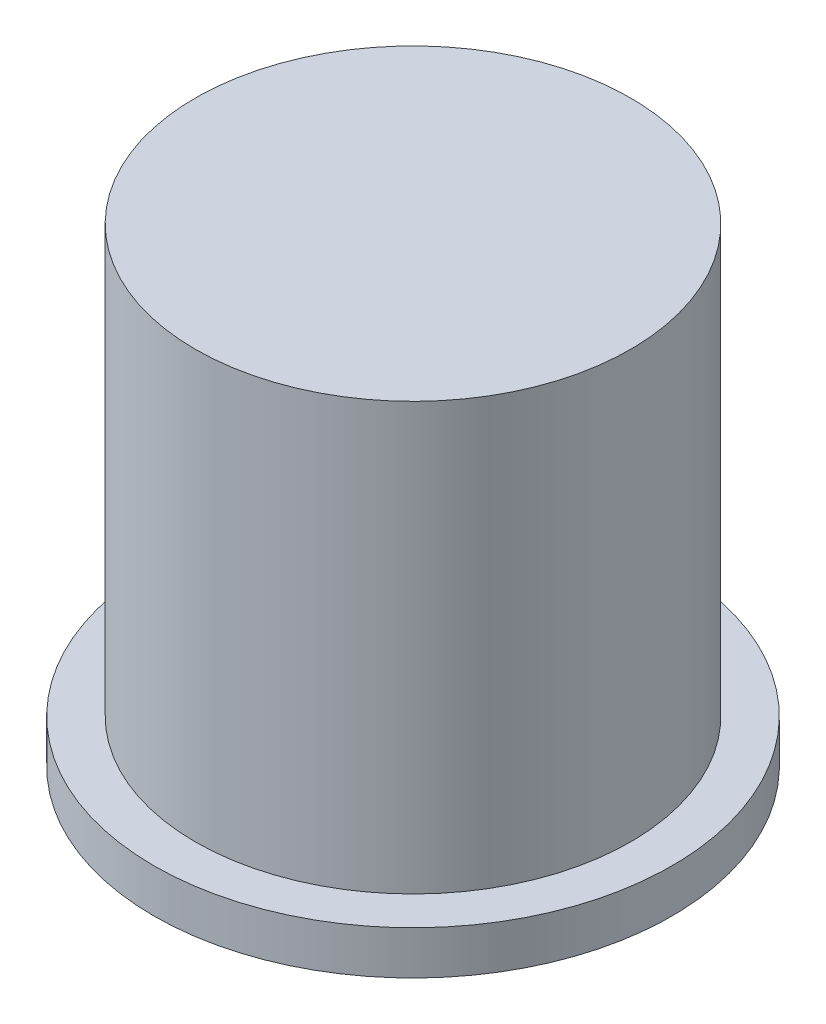
from build123d import *

# Parameters (mm, degrees)
SKETCH1_R           = 6.35
SKETCH1_R_2         = 4.699
BOSS_EXTRUDE1_DEPTH = 13.716
SKETCH2_R           = 7.5565
SKETCH2_R_2         = 6.096
BOSS_EXTRUDE2_DEPTH = 1.27
SKETCH3_R           = 6.35
BOSS_EXTRUDE3_DEPTH = 1.016


with BuildPart() as part:
    # Sketch1 → Boss-Extrude1 (new body)
    with BuildSketch(Plane(origin=(0, 0, 0), x_dir=(1, 0, 0), z_dir=(0, 1, 0))):
        Circle(SKETCH1_R)
        Circle(SKETCH1_R_2, mode=Mode.SUBTRACT)
    extrude(amount=BOSS_EXTRUDE1_DEPTH)

    # Sketch2 → Boss-Extrude2 (add)
    with BuildSketch(Plane(origin=(0, 0, 0), x_dir=(1, 0, 0), z_dir=(0, 1, 0))):
        Circle(SKETCH2_R)
        Circle(SKETCH2_R_2, mode=Mode.SUBTRACT)
    extrude(amount=BOSS_EXTRUDE2_DEPTH)

    # Sketch3 → Boss-Extrude3 (add)
    with BuildSketch(Plane(origin=(0, 13.716, 0), x_dir=(1, 0, 0), z_dir=(0, 1, 0))):
        Circle(SKETCH3_R)
    extrude(amount=-BOSS_EXTRUDE3_DEPTH)


solid = part.part
